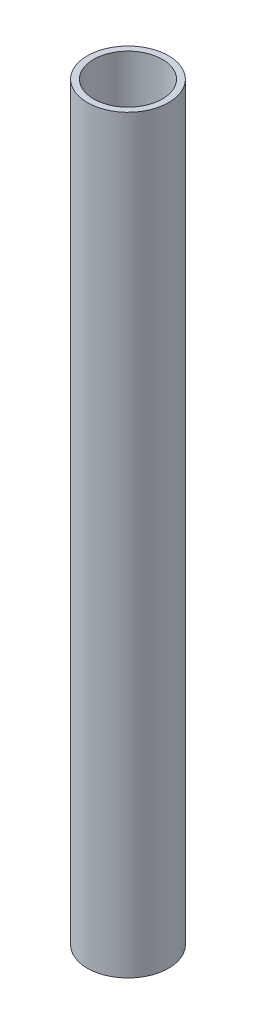
from build123d import *

# Parameters (mm, degrees)
SKETCH1_R           = 6.5
SKETCH1_R_2         = 5.5
BOSS_EXTRUDE1_DEPTH = 120


with BuildPart() as part:
    # Sketch1 → Boss-Extrude1 (new body)
    with BuildSketch(Plane(origin=(0, 0, 0), x_dir=(1, 0, 0), z_dir=(0, 1, 0))):
        Circle(SKETCH1_R)
        Circle(SKETCH1_R_2, mode=Mode.SUBTRACT)
    extrude(amount=BOSS_EXTRUDE1_DEPTH)


solid = part.part
